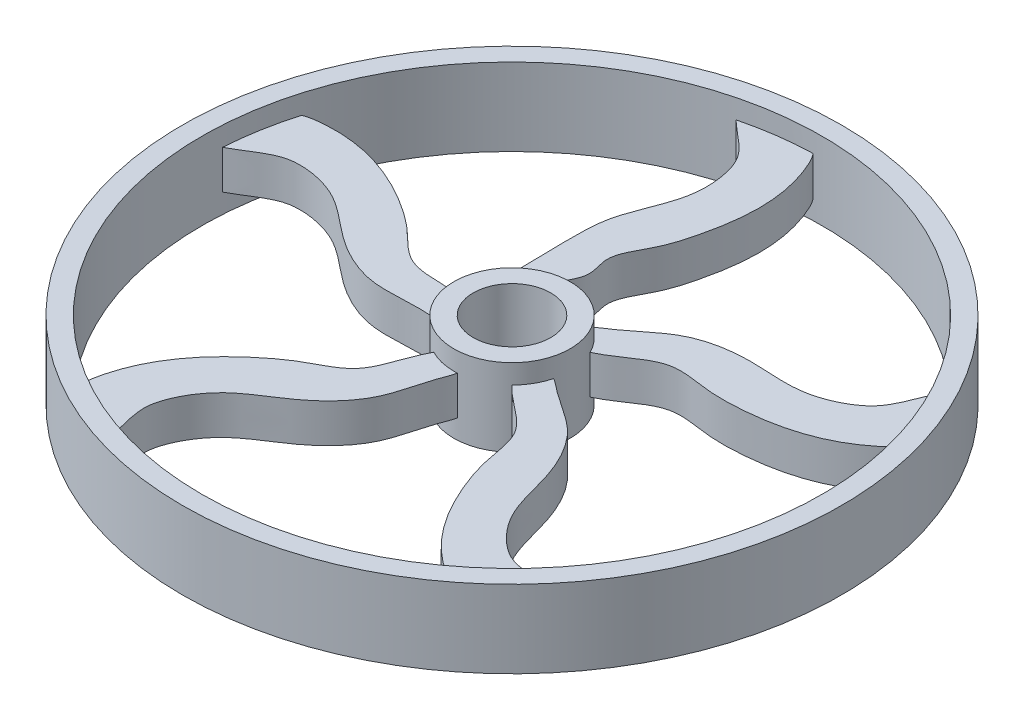
from build123d import *

# Parameters (mm, degrees)
SKETCH_1_R        = 425
SKETCH_1_R_2      = 400
EXTRUDE_1_DEPTH   = 50
SKETCH_1_R_3      = 75
SKETCH_1_R_4      = 50
EXTRUDE_1_2_DEPTH = 50
EXTRUDE_2_DEPTH   = 25


with BuildPart() as part:
    # 草图1 → 凸台-拉伸1 (new body, symmetric)
    with BuildSketch(Plane(origin=(0, 625, 0), x_dir=(-1, 0, 0), z_dir=(0, 1, 0))):
        Circle(SKETCH_1_R)
        Circle(SKETCH_1_R_2, mode=Mode.SUBTRACT)
    extrude(amount=EXTRUDE_1_DEPTH, both=True)



with BuildPart() as body_2:
    # 草图1 → Extrude 1 2 (new body, symmetric)
    with BuildSketch(Plane(origin=(0, 625, 0), x_dir=(-1, 0, 0), z_dir=(0, 1, 0))):
        Circle(SKETCH_1_R_3)
        Circle(SKETCH_1_R_4, mode=Mode.SUBTRACT)
    extrude(amount=EXTRUDE_1_2_DEPTH, both=True)


with BuildPart() as part_1:
    add(part.part)

    add(body_2.part)  # 凸台-拉伸2 merges body 2
    # 草图2 → 凸台-拉伸2 (add, symmetric)
    with BuildSketch(Plane(origin=(0, 625, 0), x_dir=(-1, 0, 0), z_dir=(0, 1, 0))):
        with BuildLine():
            add(Edge.make_bspline(
                [(101.603865915, -397.267626236), (112.5252946, -396.620000805), (67.84741669, -363.515976516), (46.009684865, -335.44935875), (39.248895885, -283.16365053), (54.189242394, -240.558276238), (73.092776541, -192.888582504), (73.502340805, -138.979763484), (71.001946466, 12.523970182), (52.994593179, -49.000362861), (-8.336296922, -53.847310697), (55.58168525, -69.616721553), (11.982287773, -111.165224687), (33.725152892, -153.244759305), (6.856216012, -191.003794872), (-7.468675899, -239.397403139), (-18.616137275, -302.891422443), (-9.764525126, -362.907361468), (14.544803628, -409.452649771), (39.508707461, -412.787356337), (54.140045243, -411.226342187), (65.381512308, -410.222991442), (79.673520632, -408.52243129), (88.150046234, -395.787431275), (99.770039561, -397.376369571), (101.603865915, -397.267626236)],
                knots=[0, 0, 0, 0, 0.046722328, 0.084692897, 0.148959813, 0.195899196, 0.235988464, 0.308133916, 0.431660576, 0.445278188, 0.495585264, 0.520132372, 0.57518688, 0.60784095, 0.662750167, 0.708381931, 0.77627002, 0.869367103, 0.908889915, 0.930743343, 0.946400909, 0.957386658, 0.967863192, 0.992154814, 1, 1, 1, 1], degree=3))
        make_face()
        with BuildLine():
            add(Edge.make_bspline(
                [(-346.426643382, -219.393466581), (-342.436316617, -229.580209932), (-324.768533244, -176.858822131), (-304.775672972, -147.419274085), (-257.40046997, -124.81896956), (-211.491258082, -125.901284998), (-163.165056543, -129.004898573), (-103.442129183, -117.127684483), (-68.572311059, -80.590762554), (-27.756458474, -57.28032557), (-46.151629786, -25.65807271), (-77.014639247, -37.390487327), (-99.719232213, -54.936814229), (-137.013058788, -76.458384121), (-179.09748592, -66.316201024), (-230.156398192, -66.579419328), (-293.743991201, -76.026449058), (-348.172044317, -102.841703154), (-384.917208185, -140.362182501), (-380.375356012, -165.133124338), (-374.369279641, -178.566201568), (-369.941257886, -188.947382602), (-363.907426344, -202.014400139), (-349.176483018, -206.140711358), (-347.096662534, -217.683001864), (-346.426643382, -219.393466581)],
                knots=[0, 0, 0, 0, 0.050211623, 0.091017892, 0.160084361, 0.210529249, 0.253612445, 0.331145831, 0.410552246, 0.43940296, 0.472324932, 0.492840003, 0.543461183, 0.578553909, 0.637563831, 0.686603445, 0.759561521, 0.859611238, 0.902085674, 0.925571149, 0.942398047, 0.954204228, 0.965463166, 0.991568924, 1, 1, 1, 1], degree=3))
        make_face()
        with BuildLine():
            add(Edge.make_bspline(
                [(-315.707306134, 261.675006979), (-324.162395994, 254.732103894), (-268.561731262, 254.220848186), (-234.384923666, 244.303828798), (-198.251013938, 206.231211448), (-185.093630416, 162.234502461), (-173.111724782, 115.31448424), (-143.360423417, 62.184866002), (-97.836379341, 40.312228051), (-63.054044261, 8.697366657), (-38.663915169, 35.964027735), (-59.359298963, 61.690978494), (-83.062952577, 77.862216383), (-115.055608061, 106.680222322), (-118.414621918, 149.838997918), (-134.443029008, 198.31757022), (-163.077335064, 255.873672174), (-205.399350592, 299.351457534), (-252.438327066, 322.703719318), (-274.593383207, 310.729519219), (-285.513019172, 300.866351998), (-294.017775068, 293.447091692), (-304.580690757, 283.670646401), (-303.952934099, 268.38558647), (-314.287604824, 262.840795725), (-315.707306134, 261.675006979)],
                knots=[0, 0, 0, 0, 0.050211623, 0.091017892, 0.160084361, 0.210529249, 0.253612445, 0.331145831, 0.410552246, 0.43940296, 0.472324932, 0.492840003, 0.543461183, 0.578553909, 0.637563831, 0.686603445, 0.759561521, 0.859611238, 0.902085674, 0.925571149, 0.942398047, 0.954204228, 0.965463166, 0.991568924, 1, 1, 1, 1], degree=3))
        make_face()
        with BuildLine():
            add(Edge.make_bspline(
                [(151.308797695, 381.1175149), (142.092938018, 387.013308164), (158.788255247, 333.975946958), (159.917823696, 298.407343863), (134.874605053, 252.276867776), (97.097103384, 226.167721666), (56.176126777, 200.273169229), (14.840514869, 155.560045258), (8.10610329, 105.505089652), (-11.213084007, 62.655593777), (22.256016074, 47.885064223), (40.328574939, 75.517608836), (48.383504315, 103.058310393), (65.90478241, 142.390387444), (105.913224809, 158.921794577), (147.066036715, 189.14641829), (192.956655337, 234.165075287), (221.228264384, 287.851078492), (228.901741995, 339.804049336), (210.667312105, 357.174528523), (197.912529562, 364.511833173), (188.228279598, 370.307659167), (175.666207139, 377.332501226), (161.323238765, 372.012125886), (152.856240511, 380.127547253), (151.308797695, 381.1175149)],
                knots=[0, 0, 0, 0, 0.050211623, 0.091017892, 0.160084361, 0.210529249, 0.253612445, 0.331145831, 0.410552246, 0.43940296, 0.472324932, 0.492840003, 0.543461183, 0.578553909, 0.637563831, 0.686603445, 0.759561521, 0.859611238, 0.902085674, 0.925571149, 0.942398047, 0.954204228, 0.965463166, 0.991568924, 1, 1, 1, 1], degree=3))
        make_face()
        with BuildLine():
            add(Edge.make_bspline(
                [(409.221285906, -26.131429062), (411.98066125, -15.54472535), (366.698270019, -47.812361541), (333.219574117, -59.877947798), (281.60810408, -50.315532588), (245.102940517, -22.455163313), (207.830480487, 8.461141378), (152.532366017, 33.956529259), (102.84622669, 24.89350334), (56.123977226, 30.025919882), (52.418889556, -6.369430492), (84.283728993, -15.018529484), (112.965602738, -14.168677737), (155.787003611, -18.67812321), (183.872594709, -51.619927316), (225.334838289, -81.418654866), (282.331106418, -111.151696668), (342.125937253, -121.449707328), (393.907383703, -112.693267314), (404.792942406, -89.983520676), (407.82968924, -75.585649795), (410.349249503, -64.584372032), (413.148377444, -50.466335583), (403.656178831, -38.469448445), (408.757956852, -27.909051463), (409.221285906, -26.131429062)],
                knots=[0, 0, 0, 0, 0.050211623, 0.091017892, 0.160084361, 0.210529249, 0.253612445, 0.331145831, 0.410552246, 0.43940296, 0.472324932, 0.492840003, 0.543461183, 0.578553909, 0.637563831, 0.686603445, 0.759561521, 0.859611238, 0.902085674, 0.925571149, 0.942398047, 0.954204228, 0.965463166, 0.991568924, 1, 1, 1, 1], degree=3))
        make_face()
    extrude(amount=EXTRUDE_2_DEPTH, both=True)


solid = part_1.part
